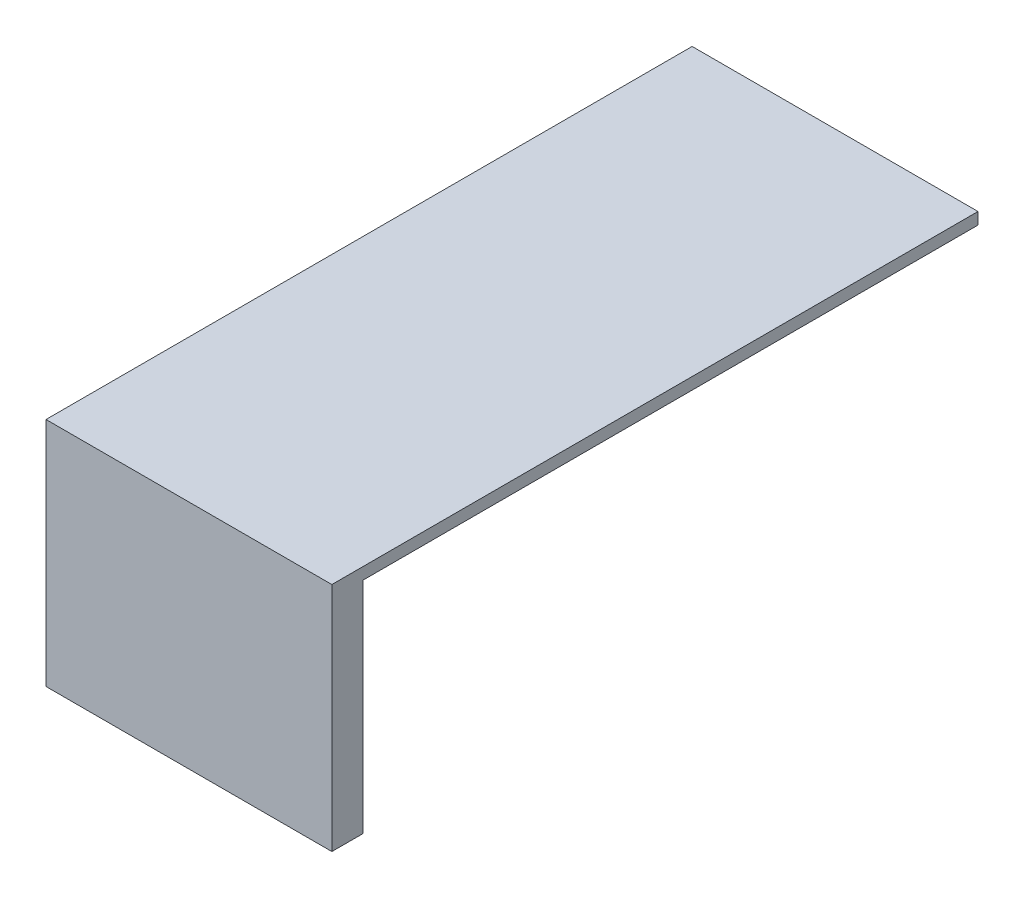
from build123d import *

# Parameters (mm, degrees)
SKETCH1_R           = 28.1
BOSS_EXTRUDE1_DEPTH = 1
SKETCH2_R           = 18.6
CUT_EXTRUDE1_DEPTH  = 58.8
SKETCH3_W           = 222.683092022
SKETCH3_H           = 364.2827524
BOSS_EXTRUDE2_DEPTH = 58.8
SKETCH4_W           = 207.917403516
SKETCH4_H           = 348.54429772
CUT_EXTRUDE2_DEPTH  = 55.8
SKETCH9_R           = 3
CUT_EXTRUDE8_DEPTH  = 10
SKETCH10_R          = 3.75
CUT_EXTRUDE9_DEPTH  = 10
CUT_EXTRUDE13_DEPTH = 500
SKETCH6_R           = 3.75
CUT_EXTRUDE5_DEPTH  = 400
SKETCH8_R           = 10
CUT_EXTRUDE7_DEPTH  = 10


with BuildPart() as part:
    # Sketch1 → Boss-Extrude1 (new body)
    with BuildSketch(Plane(origin=(0, 0, 0), x_dir=(1, 0, 0), z_dir=(0, 1, 0))):
        Circle(SKETCH1_R)
    extrude(amount=BOSS_EXTRUDE1_DEPTH)

    # Sketch2 → Cut-Extrude1 (cut)
    with BuildSketch(Plane(origin=(0, 1, 0), x_dir=(1, 0, 0), z_dir=(0, 1, 0))):
        with Locations((0, -7)):
            Circle(SKETCH2_R)
    extrude(amount=-CUT_EXTRUDE1_DEPTH, mode=Mode.SUBTRACT)

    # Sketch3 → Boss-Extrude2 (add)
    with BuildSketch(Plane(origin=(0, 0, 0), x_dir=(-1, 0, 0), z_dir=(0, -1, 0))):
        Rectangle(SKETCH3_W, SKETCH3_H)
    extrude(amount=BOSS_EXTRUDE2_DEPTH)

    # Sketch4 → Cut-Extrude2 (cut)
    with BuildSketch(Plane(origin=(0, -58.8, 0), x_dir=(-1, 0, 0), z_dir=(0, -1, 0))):
        Rectangle(SKETCH4_W, SKETCH4_H)
    extrude(amount=-CUT_EXTRUDE2_DEPTH, mode=Mode.SUBTRACT)

    # Sketch9 → Cut-Extrude8 (cut)
    with BuildSketch(Plane(origin=(0, 0, 0), x_dir=(1, 0, 0), z_dir=(0, 1, 0))):
        with Locations((0, -7)):
            Circle(SKETCH9_R)
    extrude(amount=-CUT_EXTRUDE8_DEPTH, mode=Mode.SUBTRACT)

    # Sketch10 → Cut-Extrude9 (cut)
    with BuildSketch(Plane(origin=(0, 1, 0), x_dir=(1, 0, 0), z_dir=(0, 1, 0))):
        with Locations((0, 19.85)):
            Circle(SKETCH10_R)
    extrude(amount=-CUT_EXTRUDE9_DEPTH, mode=Mode.SUBTRACT)

    # Sketch11 → Cut-Extrude13 (cut)
    with BuildSketch(Plane(origin=(0, -58.8, 0), x_dir=(-1, 0, 0), z_dir=(0, -1, 0))):
        Polygon((38.658453989, -17.8586238), (38.658453989, -182.1413762), (-111.341546011, -182.1413762), (-111.341546011, 182.1413762), (111.341546011, 182.1413762), (111.341546011, -17.8586238), align=None)
    extrude(amount=-CUT_EXTRUDE13_DEPTH, mode=Mode.SUBTRACT)

    # Sketch6 → Cut-Extrude5 (cut)
    with BuildSketch(Plane(origin=(0, 1, 0), x_dir=(1, 0, 0), z_dir=(0, 1, 0))):
        with Locations((0, 18.75)):
            Circle(SKETCH6_R)
    extrude(amount=-CUT_EXTRUDE5_DEPTH, mode=Mode.SUBTRACT)

    # Sketch8 → Cut-Extrude7 (cut)
    with BuildSketch(Plane(origin=(0, 0, -182.1413762), x_dir=(-1, 0, 0), z_dir=(0, 0, -1))):
        with Locations((-86.573671766, -25.011155335)):
            Circle(SKETCH8_R)
    extrude(amount=-CUT_EXTRUDE7_DEPTH, mode=Mode.SUBTRACT)


solid = part.part
